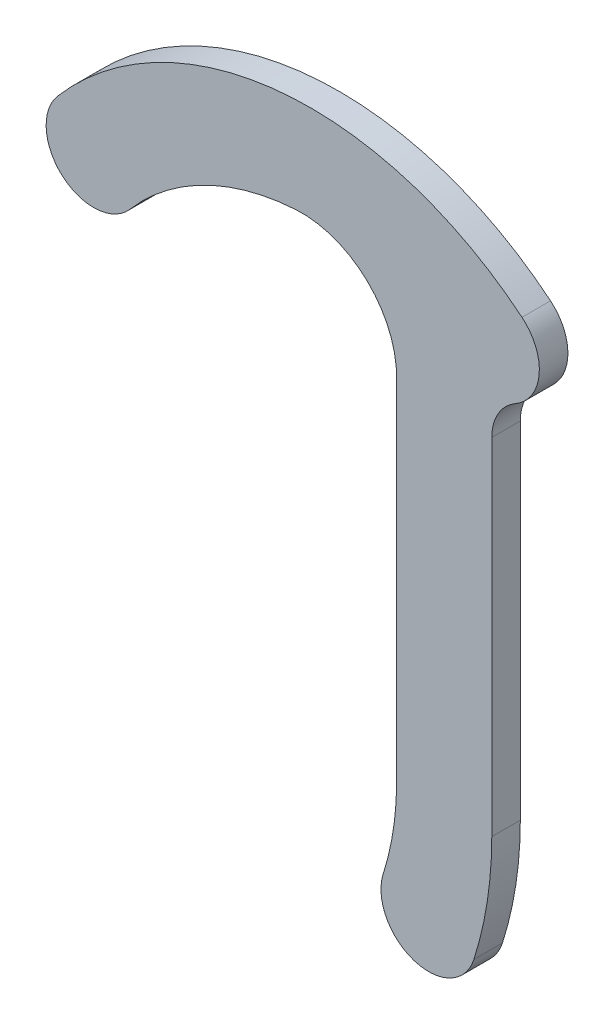
from build123d import *

# Parameters (mm, degrees)
BOSS_EXTRU_1_DEPTH      = 1.5
BOSS_EXTRU_2_DEPTH      = 3
ESQUISSE2_R             = 2.5
ENL_V_MAT_EXTRU_3_DEPTH = 2
CONG_1_R                = 10


with BuildPart() as part:
    # Esquisse1 → Boss.-Extru.1 (new body, symmetric)
    with BuildSketch(Plane.XY):
        with BuildLine():
            Line((-10, -45), (-10, -8.660254038))
            ThreePointArc((-10, -8.660254038), (-7.990381057, -1.160254038), (-2.5, 4.330127019))
            ThreePointArc((-2.5, 4.330127019), (4.330127019, 2.5), (2.5, -4.330127019))
            ThreePointArc((2.5, -4.330127019), (0.669872981, -6.160254038), (0, -8.660254038))
            Line((0, -8.660254038), (0, -45))
            ThreePointArc((0, -45), (-0.472828873, -51.132107527), (-1.880137136, -57.11924318))
            ThreePointArc((-1.880137136, -57.11924318), (-8.160025392, -60.369320641), (-11.410102852, -54.089432385))
            ThreePointArc((-11.410102852, -54.089432385), (-10.354621655, -49.599080646), (-10, -45))
        make_face()
    extrude(amount=BOSS_EXTRU_1_DEPTH, both=True)

    # Esquisse4 → Boss.-Extru.2 (add)
    with BuildSketch(Plane.XY.offset(1.5)):
        with BuildLine():
            ThreePointArc((-38.042287627, -6.912622664), (-45.092258789, -7.458430888), (-45.638067013, -0.408459726))
            ThreePointArc((-45.638067013, -0.408459726), (-22.103290159, 11.693784424), (3.175473194, 3.862171668))
            ThreePointArc((3.175473194, 3.862171668), (3.862171668, -3.175473194), (-3.175473194, -3.862171668))
            ThreePointArc((-3.175473194, -3.862171668), (-21.231732732, 1.731837443), (-38.042287627, -6.912622664))
        make_face()
    extrude(amount=-BOSS_EXTRU_2_DEPTH)

    # Esquisse2 → Enlèv. mat.-Extru.3 (cut)
    with BuildSketch(Plane(origin=(0, 0, -1.5), x_dir=(-1, 0, 0), z_dir=(0, 0, -1))):
        Circle(ESQUISSE2_R)
    extrude(amount=-ENL_V_MAT_EXTRU_3_DEPTH, mode=Mode.SUBTRACT)

    # Congé1
    cong_1_edges = [part.edges().sort_by_distance(p)[0] for p in [
        (-7.8041925, -0.846634236, 0),
    ]]
    fillet(cong_1_edges, radius=CONG_1_R)


solid = part.part
